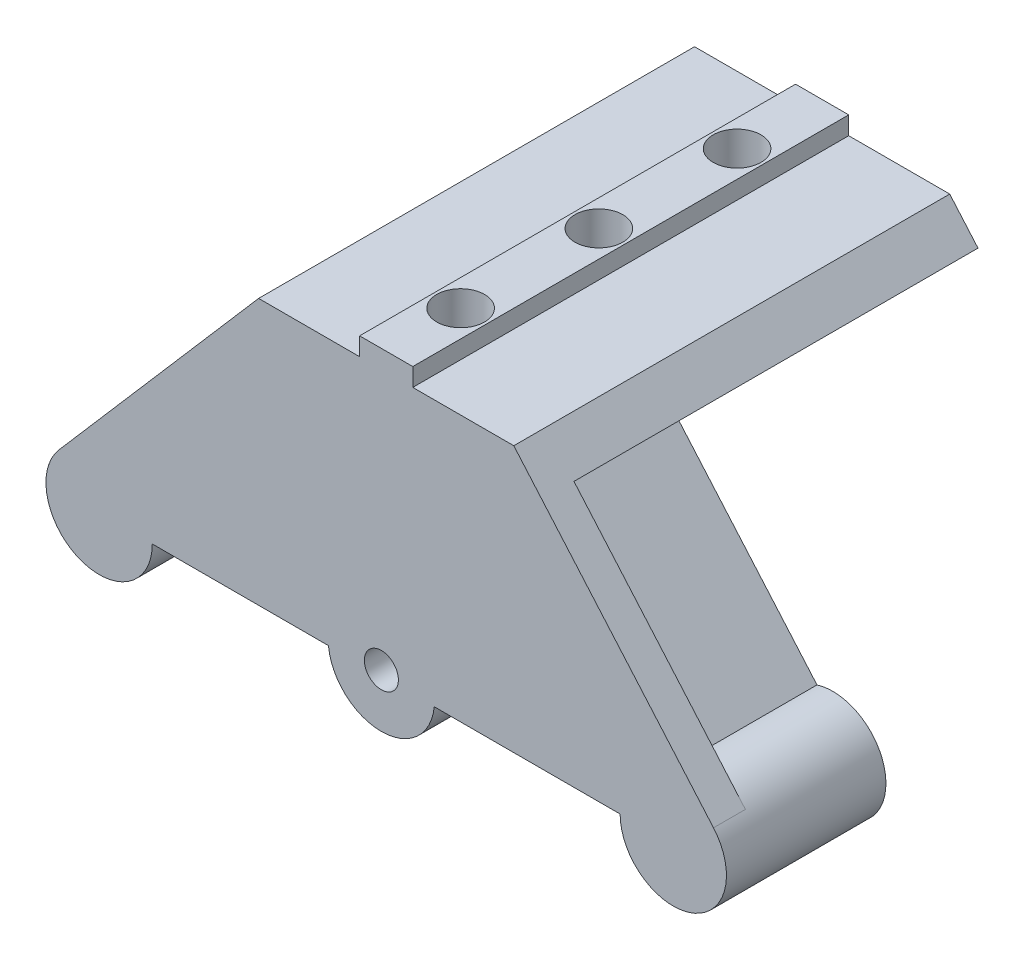
from build123d import *

# Parameters (mm, degrees)
BOSS_EXTRUDE1_DEPTH = 3
SKETCH2_R           = 3.39
BOSS_EXTRUDE2_DEPTH = 12
BOSS_EXTRUDE3_DEPTH = 26
SKETCH7_W           = 5
SKETCH7_H           = 1.7
BOSS_EXTRUDE5_DEPTH = 41
SKETCH4_R           = 2.25
CUT_EXTRUDE1_DEPTH  = 13
SKETCH8_R           = 4
CUT_EXTRUDE3_DEPTH  = 4.5
LPATTERN1_COUNT     = 3
LPATTERN1_PITCH     = 13
SKETCH5_R           = 5
BOSS_EXTRUDE4_DEPTH = 3
SKETCH6_R           = 1.6
CUT_EXTRUDE2_DEPTH  = 3


with BuildPart() as part:
    # Sketch1 → Boss-Extrude1 (new body)
    with BuildSketch(Plane.XY):
        with BuildLine():
            Line((-22, 0), (22, 0))
            ThreePointArc((22, 0), (28.74444357, -4.685820806), (30.782766652, 3.269659991))
            Line((30.782766652, 3.269659991), (12, 25))
            Line((12, 25), (-12, 25))
            Line((-12, 25), (-30.782766652, 3.269659991))
            ThreePointArc((-30.782766652, 3.269659991), (-28.74444357, -4.685820806), (-22, 0))
        make_face()
    extrude(amount=-BOSS_EXTRUDE1_DEPTH)

    # Sketch2 → Boss-Extrude2 (add)
    with BuildSketch(Plane(origin=(0, 0, -3), x_dir=(-1, 0, 0), z_dir=(0, 0, -1))):
        with BuildLine():
            Line((10.11979413, 18), (-10.11979413, 18))
            Line((-10.11979413, 18), (-23.039847225, 3.052407247))
            ThreePointArc((-23.039847225, 3.052407247), (-29.854865308, -4.104843977), (-25.51641378, 4.7748269))
            Line((-25.51641378, 4.7748269), (-12.389454122, 19.961795995))
            Line((-12.389454122, 19.961795995), (-14.659114113, 21.923591989))
            Line((-14.659114113, 21.923591989), (-12, 25))
            Line((-12, 25), (12, 25))
            Line((12, 25), (14.659114113, 21.923591989))
            Line((14.659114113, 21.923591989), (12.389454122, 19.961795995))
            Line((12.389454122, 19.961795995), (25.51641378, 4.7748269))
            ThreePointArc((25.51641378, 4.7748269), (29.854865308, -4.104843977), (23.039847225, 3.052407247))
            Line((23.039847225, 3.052407247), (10.11979413, 18))
        make_face()
        with Locations((27, 0)):
            Circle(SKETCH2_R, mode=Mode.SUBTRACT)
        with Locations((-27, 0)):
            Circle(SKETCH2_R, mode=Mode.SUBTRACT)
    extrude(amount=BOSS_EXTRUDE2_DEPTH)

    # Sketch3 → Boss-Extrude3 (add)
    with BuildSketch(Plane(origin=(0, 0, -15), x_dir=(-1, 0, 0), z_dir=(0, 0, -1))):
        Polygon((14.659114113, 21.923591989), (10.11979413, 18), (-10.11979413, 18), (-14.659114113, 21.923591989), (-12, 25), (12, 25), align=None)
    extrude(amount=BOSS_EXTRUDE3_DEPTH)

    # Sketch7 → Boss-Extrude5 (add)
    with BuildSketch(Plane(origin=(0, 0, -41), x_dir=(-1, 0, 0), z_dir=(0, 0, -1))):
        with Locations((0, 25.85)):
            Rectangle(SKETCH7_W, SKETCH7_H)
    extrude(amount=-BOSS_EXTRUDE5_DEPTH)

    # Sketch4 → Cut-Extrude1 (cut, symmetric)
    with BuildSketch(Plane(origin=(0, 25, 0), x_dir=(-1, 0, 0), z_dir=(0, 1, 0))):
        with Locations((0, -33)):
            Circle(SKETCH4_R)
        with Locations((0, -20)):
            Circle(SKETCH4_R)
        with Locations((0, -7)):
            Circle(SKETCH4_R)
    extrude(amount=CUT_EXTRUDE1_DEPTH, both=True, mode=Mode.SUBTRACT)

    # Sketch8 → Cut-Extrude3 (cut)
    with BuildSketch(Plane(origin=(0, 18, 0), x_dir=(-1, 0, 0), z_dir=(0, -1, 0))):
        with Locations((0, 33)):
            Circle(SKETCH8_R)
    cut_extrude3 = extrude(amount=-CUT_EXTRUDE3_DEPTH, mode=Mode.SUBTRACT)

    # LPattern1: Cut-Extrude3 ×3
    with Locations(*[(0, 0, i * LPATTERN1_PITCH) for i in range(1, LPATTERN1_COUNT)]):
        add(cut_extrude3, mode=Mode.SUBTRACT)

    # Sketch5 → Boss-Extrude4 (add)
    with BuildSketch(Plane.XY):
        with Locations((-0.455639948, 0.495332174)):
            Circle(SKETCH5_R)
    extrude(amount=-BOSS_EXTRUDE4_DEPTH)

    # Sketch6 → Cut-Extrude2 (cut)
    with BuildSketch(Plane.XY):
        with Locations((-0.455639948, 0.495332174)):
            Circle(SKETCH6_R)
    extrude(amount=-CUT_EXTRUDE2_DEPTH, mode=Mode.SUBTRACT)


solid = part.part
